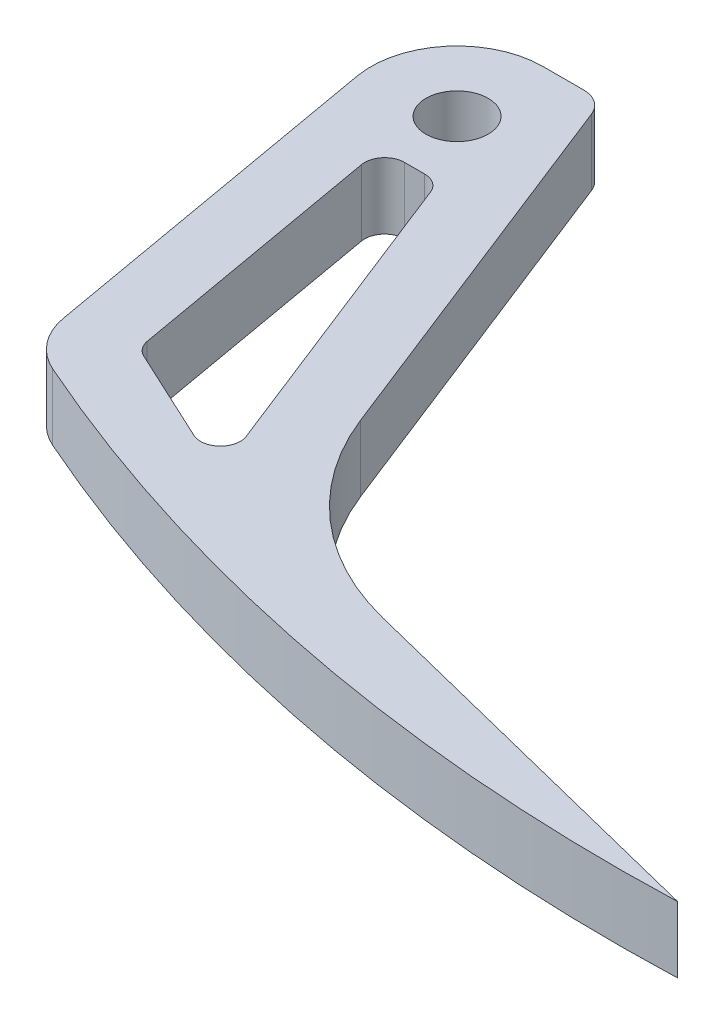
from build123d import *

# Parameters (mm, degrees)
SKETCH1_R           = 2.9845
BOSS_EXTRUDE1_DEPTH = 6.35
CUT_EXTRUDE1_DEPTH  = 7.35
FILLET1_R           = 25.4
FILLET2_R           = 6.35
FILLET3_R           = 1.905
FILLET4_R           = 2.54


with BuildPart() as part:
    # Sketch1 → Boss-Extrude1 (new body)
    with BuildSketch(Plane(origin=(0, 0, 0), x_dir=(1, 0, 0), z_dir=(0, 1, 0))):
        with BuildLine():
            Line((7.682408093, 3.020865917), (5.624249106, 8.255))
            Line((5.624249106, 8.255), (0, 8.255))
            ThreePointArc((0, 8.255), (-6.323696878, 5.306211718), (-8.129588001, -1.433465707))
            Line((-8.129588001, -1.433465707), (-1.513592432, -38.954641096))
            ThreePointArc((-1.513592432, -38.954641096), (33.306036144, -50.744311292), (69.85, -54.737))
            ThreePointArc((69.85, -54.737), (72.817340251, -54.71098351), (75.783768162, -54.632942041))
            Line((75.783768162, -54.632942041), (25.4, -42.037))
            Line((25.4, -42.037), (7.682408093, 3.020865917))
        make_face()
        Circle(SKETCH1_R, mode=Mode.SUBTRACT)
    extrude(amount=BOSS_EXTRUDE1_DEPTH)

    # Sketch2 → Cut-Extrude1 (cut, through all)
    with BuildSketch(Plane(origin=(0, 6.35, 0), x_dir=(1, 0, 0), z_dir=(0, 1, 0))):
        Polygon((4.007338902, -34.519082642), (18.219473265, -41.128490063), (4.543923357, -6.35), (-0.959630389, -6.35), align=None)
    extrude(amount=-CUT_EXTRUDE1_DEPTH, mode=Mode.SUBTRACT)

    # Fillet1
    fillet1_edges = [part.edges().sort_by_distance(p)[0] for p in [
        (25.4, 3.175, 42.037),
    ]]
    fillet(fillet1_edges, radius=FILLET1_R)

    # Fillet2
    fillet2_edges = [part.edges().sort_by_distance(p)[0] for p in [
        (-1.513592432, 3.175, 38.954641096),
    ]]
    fillet(fillet2_edges, radius=FILLET2_R)

    # Fillet3
    fillet3_edges = [part.edges().sort_by_distance(p)[0] for p in [
        (-0.959630389, 3.175, 6.35),
        (4.543923357, 3.175, 6.35),
        (18.219473265, 3.175, 41.128490063),
        (4.007338902, 3.175, 34.519082642),
    ]]
    fillet(fillet3_edges, radius=FILLET3_R)

    # Fillet4
    fillet4_edges = [part.edges().sort_by_distance(p)[0] for p in [
        (5.624249106, 3.175, -8.255),
    ]]
    fillet(fillet4_edges, radius=FILLET4_R)


solid = part.part
